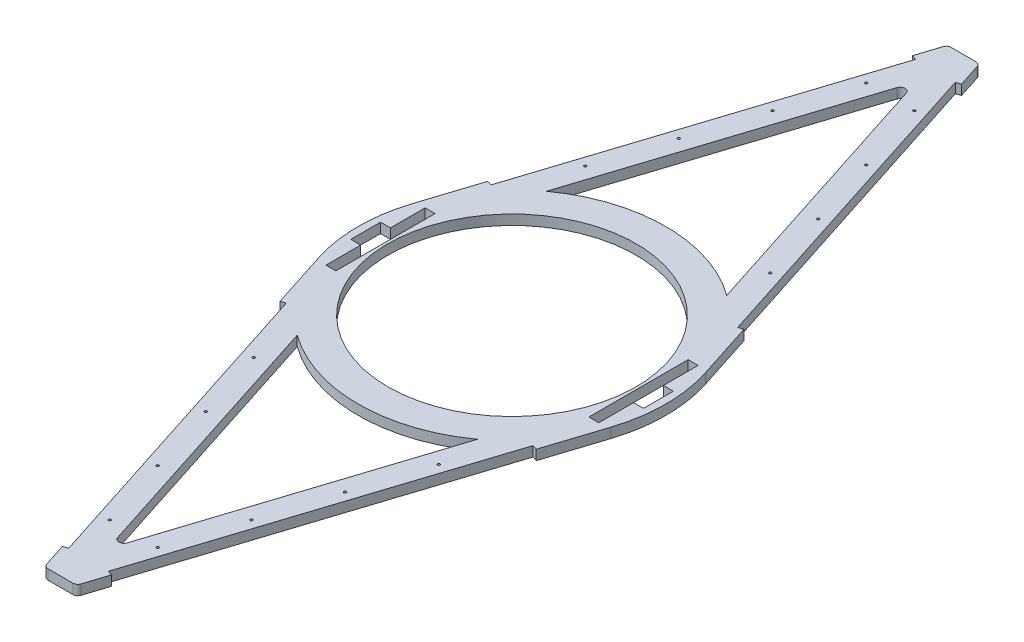
from build123d import *

# Parameters (mm, degrees)
SKETCH2_R           = 2.5
SKETCH2_R_2         = 250
BOSS_EXTRUDE1_DEPTH = 20
CUT_EXTRUDE4_DEPTH  = 21
CUT_EXTRUDE5_DEPTH  = 21


with BuildPart() as part:
    # Sketch2 → Boss-Extrude1 (new body)
    with BuildSketch(Plane(origin=(0, 0, 0), x_dir=(1, 0, 0), z_dir=(0, 1, 0))):
        with BuildLine():
            Line((-34.517430478, 903.068960265), (-295.040344804, 95.1377682))
            ThreePointArc((-295.040344804, 95.1377682), (-310, 0), (-295.040344804, -95.1377682))
            Line((-295.040344804, -95.1377682), (-34.517430478, -903.068960265))
            ThreePointArc((-34.517430478, -903.068960265), (-30.886866626, -908.083613135), (-25, -910))
            Line((-25, -910), (25, -910))
            ThreePointArc((25, -910), (30.886866626, -908.083613135), (34.517430478, -903.068960265))
            Line((34.517430478, -903.068960265), (295.040344804, -95.1377682))
            ThreePointArc((295.040344804, -95.1377682), (310, 0), (295.040344804, 95.1377682))
            Line((295.040344804, 95.1377682), (34.517430478, 903.068960265))
            ThreePointArc((34.517430478, 903.068960265), (30.886866626, 908.083613135), (25, 910))
            Line((25, 910), (-25, 910))
            ThreePointArc((-25, 910), (-30.886866626, 908.083613135), (-34.517430478, 903.068960265))
        make_face()
        with Locations((-48.373467006, -762.345774842)):
            Circle(SKETCH2_R, mode=Mode.SUBTRACT)
        with Locations((-94.407870974, -619.584317679)):
            Circle(SKETCH2_R, mode=Mode.SUBTRACT)
        with Locations((-140.442274942, -476.822860516)):
            Circle(SKETCH2_R, mode=Mode.SUBTRACT)
        with BuildLine():
            ThreePointArc((-181.680791071, -251.181388952), (0, -310), (181.680791071, -251.181388952))
            Line((181.680791071, -251.181388952), (9.517430478, -785.092770658))
            ThreePointArc((9.517430478, -785.092770658), (0, -792.023810393), (-9.517430478, -785.092770658))
            Line((-9.517430478, -785.092770658), (-181.680791071, -251.181388952))
        make_face(mode=Mode.SUBTRACT)
        with Locations((-186.476678909, -334.061403353)):
            Circle(SKETCH2_R, mode=Mode.SUBTRACT)
        with Locations((48.373467006, -762.345774842)):
            Circle(SKETCH2_R, mode=Mode.SUBTRACT)
        with Locations((94.407870974, -619.584317679)):
            Circle(SKETCH2_R, mode=Mode.SUBTRACT)
        with Locations((140.442274942, -476.822860516)):
            Circle(SKETCH2_R, mode=Mode.SUBTRACT)
        with Locations((186.476678909, -334.061403353)):
            Circle(SKETCH2_R, mode=Mode.SUBTRACT)
        with Locations((-186.476678909, 334.061403353)):
            Circle(SKETCH2_R, mode=Mode.SUBTRACT)
        with Locations((-140.442274942, 476.822860516)):
            Circle(SKETCH2_R, mode=Mode.SUBTRACT)
        with Locations((-94.407870974, 619.584317679)):
            Circle(SKETCH2_R, mode=Mode.SUBTRACT)
        with BuildLine():
            ThreePointArc((181.680791071, 251.181388952), (0, 310), (-181.680791071, 251.181388952))
            Line((-181.680791071, 251.181388952), (-9.517430478, 785.092770658))
            ThreePointArc((-9.517430478, 785.092770658), (0, 792.023810393), (9.517430478, 785.092770658))
            Line((9.517430478, 785.092770658), (181.680791071, 251.181388952))
        make_face(mode=Mode.SUBTRACT)
        with Locations((-48.373467006, 762.345774842)):
            Circle(SKETCH2_R, mode=Mode.SUBTRACT)
        Circle(SKETCH2_R_2, mode=Mode.SUBTRACT)
        with Locations((186.476678909, 334.061403353)):
            Circle(SKETCH2_R, mode=Mode.SUBTRACT)
        with Locations((140.442274942, 476.822860516)):
            Circle(SKETCH2_R, mode=Mode.SUBTRACT)
        with Locations((94.407870974, 619.584317679)):
            Circle(SKETCH2_R, mode=Mode.SUBTRACT)
        with Locations((48.373467006, 762.345774842)):
            Circle(SKETCH2_R, mode=Mode.SUBTRACT)
    extrude(amount=BOSS_EXTRUDE1_DEPTH)

    # Sketch3 → Cut-Extrude4 (cut, through all)
    with BuildSketch(Plane(origin=(0, 20, 0), x_dir=(1, 0, 0), z_dir=(0, 1, 0))):
        Polygon((-49.523523643, -856.532206403), (-40.006093165, -853.463246139), (-248.695391152, -206.277973666), (-258.21282163, -209.34693393), align=None)
        Polygon((-49.523523643, 856.532206403), (-40.006093165, 853.463246139), (-248.695391152, 206.277973666), (-258.21282163, 209.34693393), align=None)
        Polygon((49.523523643, 856.532206403), (40.006093165, 853.463246139), (248.695391152, 206.277973666), (258.21282163, 209.34693393), align=None)
        Polygon((49.523523643, -856.532206403), (40.006093165, -853.463246139), (248.695391152, -206.277973666), (258.21282163, -209.34693393), align=None)
    extrude(amount=-CUT_EXTRUDE4_DEPTH, mode=Mode.SUBTRACT)

    # Sketch4 → Cut-Extrude5 (cut, through all)
    with BuildSketch(Plane(origin=(0, 20, 0), x_dir=(1, 0, 0), z_dir=(0, 1, 0))):
        Polygon((-255, -100), (-255, 100), (-275, 100), (-275, 30), (-295, 30), (-295, -30), (-275, -30), (-275, -100), align=None)
        Polygon((255, -100), (275, -100), (275, -30), (295, -30), (295, 30), (275, 30), (275, 100), (255, 100), align=None)
    extrude(amount=-CUT_EXTRUDE5_DEPTH, mode=Mode.SUBTRACT)


solid = part.part
